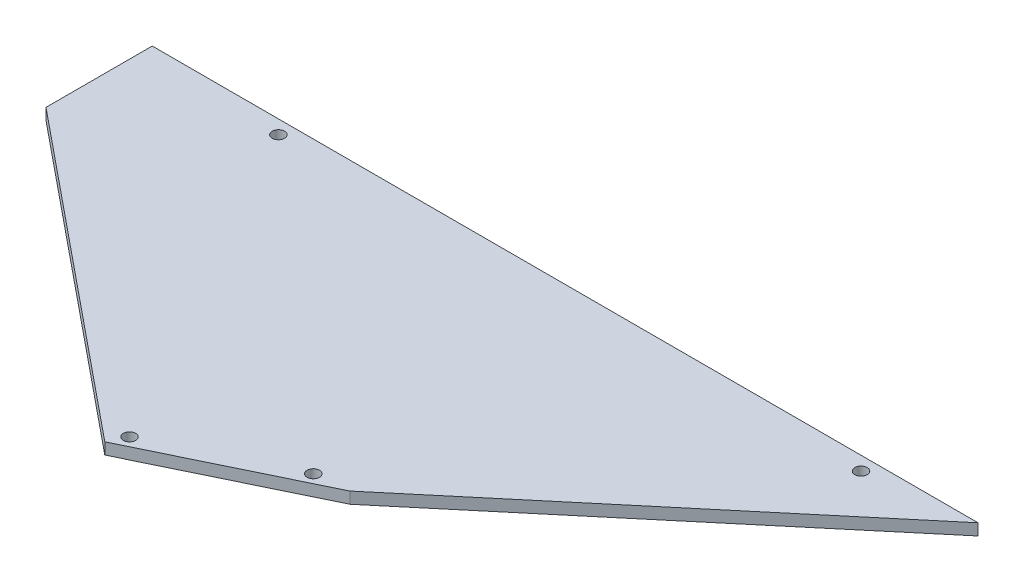
from build123d import *

# Parameters (mm, degrees)
SKETCH1_R           = 3.429
BOSS_EXTRUDE1_DEPTH = 6.35


with BuildPart() as part:
    # Sketch1 → Boss-Extrude1 (new body)
    with BuildSketch(Plane(origin=(0, 0, 0), x_dir=(1, 0, 0), z_dir=(0, 1, 0))):
        Polygon((-189.09320701, -158.66804026), (-280.551178696, -202.917327431), (-457.2, -58.822791946), (-457.2, 0), (0, 0), align=None)
        with Locations((-207.494657953, -160.516879503)):
            Circle(SKETCH1_R, mode=Mode.SUBTRACT)
        with Locations((-276.088136717, -193.703844882)):
            Circle(SKETCH1_R, mode=Mode.SUBTRACT)
        with Locations((-57.15, -7.62)):
            Circle(SKETCH1_R, mode=Mode.SUBTRACT)
        with Locations((-379.73, -7.62)):
            Circle(SKETCH1_R, mode=Mode.SUBTRACT)
    extrude(amount=BOSS_EXTRUDE1_DEPTH)


solid = part.part
